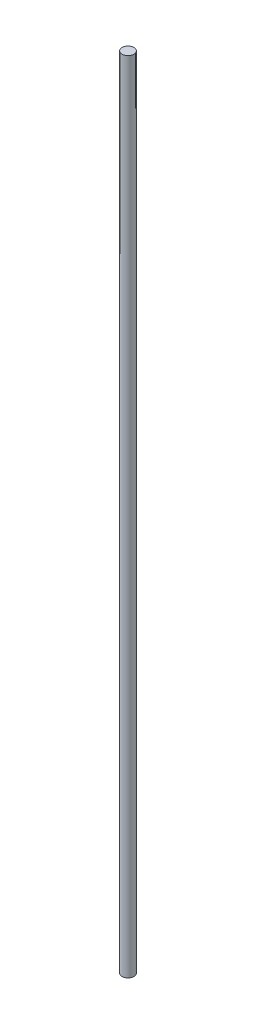
from build123d import *

# Parameters (mm, degrees)
CROQUIS1_R = 6.35


with BuildPart() as part:
    # Barrer1: sweep along a path in Croquis2
    with BuildLine(Plane.XY) as barrer1_path:
        Line((0, 0), (0, 860))
    # Croquis1 → Barrer1 (sweep)
    with BuildSketch(Plane(origin=(0, 0, 0), x_dir=(1, 0, 0), z_dir=(0, 1, 0))):
        Circle(CROQUIS1_R)
    sweep(path=barrer1_path.line)


solid = part.part
